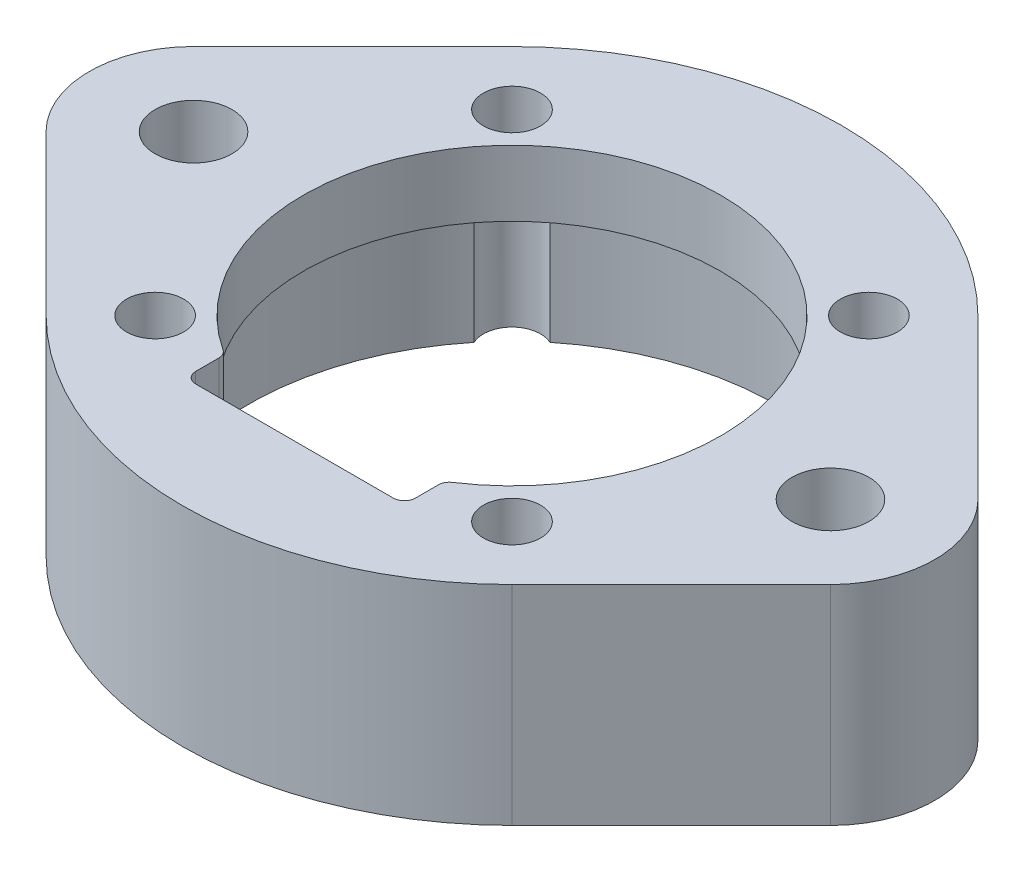
from build123d import *

# Parameters (mm, degrees)
SKETCH1_R           = 12
SKETCH1_R_2         = 1.75
BOSS_EXTRUDE1_DEPTH = 9.5
SKETCH3_R           = 12
SKETCH3_R_2         = 9.5
BOSS_EXTRUDE2_DEPTH = 3
SKETCH4_R           = 1.3
CUT_EXTRUDE1_DEPTH  = 10.5
SKETCH5_W           = 10
SKETCH5_H           = 5
CUT_EXTRUDE2_DEPTH  = 3
FILLET1_R           = 0.5


with BuildPart() as part:
    # Sketch1 → Boss-Extrude1 (new body)
    with BuildSketch(Plane(origin=(0, 0, 0), x_dir=(1, 0, 0), z_dir=(0, 1, 0))):
        with BuildLine():
            Line((-17.857758621, 3.359755504), (-10.603448276, 10.609754222))
            ThreePointArc((-10.603448276, 10.609754222), (0, 15), (10.603448276, 10.609754222))
            Line((10.603448276, 10.609754222), (17.857758621, 3.359755504))
            ThreePointArc((17.857758621, 3.359755504), (19.25, 0), (17.857758621, -3.359755504))
            Line((17.857758621, -3.359755504), (10.603448276, -10.609754222))
            ThreePointArc((10.603448276, -10.609754222), (0, -15), (-10.603448276, -10.609754222))
            Line((-10.603448276, -10.609754222), (-17.857758621, -3.359755504))
            ThreePointArc((-17.857758621, -3.359755504), (-19.25, 0), (-17.857758621, 3.359755504))
        make_face()
        Circle(SKETCH1_R, mode=Mode.SUBTRACT)
        with Locations((-14.5, 0)):
            Circle(SKETCH1_R_2, mode=Mode.SUBTRACT)
        with Locations((14.5, 0)):
            Circle(SKETCH1_R_2, mode=Mode.SUBTRACT)
    extrude(amount=BOSS_EXTRUDE1_DEPTH)

    # Sketch3 → Boss-Extrude2 (add)
    with BuildSketch(Plane(origin=(0, 9.5, 0), x_dir=(1, 0, 0), z_dir=(0, 1, 0))):
        Circle(SKETCH3_R)
        Circle(SKETCH3_R_2, mode=Mode.SUBTRACT)
    extrude(amount=-BOSS_EXTRUDE2_DEPTH)

    # Sketch4 → Cut-Extrude1 (cut, through all)
    with BuildSketch(Plane(origin=(0, 9.5, 0), x_dir=(1, 0, 0), z_dir=(0, 1, 0))):
        with Locations((8.125, 8.125)):
            Circle(SKETCH4_R)
        with Locations((-8.125, 8.125)):
            Circle(SKETCH4_R)
        with Locations((-8.125, -8.125)):
            Circle(SKETCH4_R)
        with Locations((8.125, -8.125)):
            Circle(SKETCH4_R)
    extrude(amount=-CUT_EXTRUDE1_DEPTH, mode=Mode.SUBTRACT)

    # Sketch5 → Cut-Extrude2 (cut)
    with BuildSketch(Plane(origin=(0, 9.5, 0), x_dir=(1, 0, 0), z_dir=(0, 1, 0))):
        with Locations((0, -7.4)):
            Rectangle(SKETCH5_W, SKETCH5_H)
    extrude(amount=-CUT_EXTRUDE2_DEPTH, mode=Mode.SUBTRACT)

    # Fillet1
    fillet1_edges = [part.edges().sort_by_distance(p)[0] for p in [
        (-5, 8, 8.077747211),
        (5, 8, 8.077747211),
        (-5, 8, 9.9),
        (5, 8, 9.9),
    ]]
    fillet(fillet1_edges, radius=FILLET1_R)


solid = part.part
